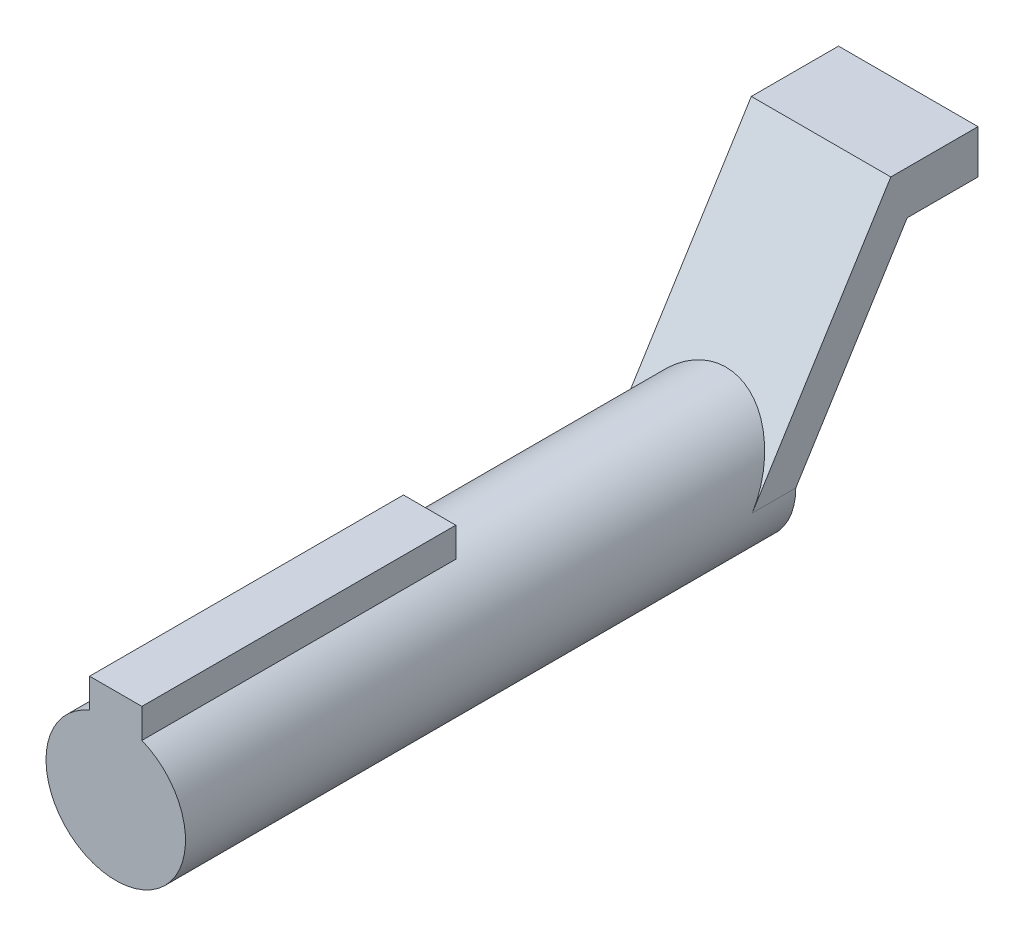
from build123d import *

# Parameters (mm, degrees)
SKETCH1_R                = 4
BOSS_EXTRUDE1_DEPTH      = 35
BOSS_EXTRUDE2_DEPTH      = 4
BOSS_EXTRUDE2_DEPTH_BACK = 4
SKETCH4_W                = 3
SKETCH4_H                = 5.4
BOSS_EXTRUDE3_DEPTH      = 18


with BuildPart() as part:
    # Sketch1 → Boss-Extrude1 (new body)
    with BuildSketch(Plane.XY):
        Circle(SKETCH1_R)
    extrude(amount=BOSS_EXTRUDE1_DEPTH)

    # Sketch2 → Boss-Extrude2 (add, two sides)
    with BuildSketch(Plane(origin=(0, 0, 0), x_dir=(0, 0, -1), z_dir=(1, 0, 0))) as boss_extrude2_sk:
        Polygon((5.4499841, 12.71997456), (-2.5, 0), (0, 0), (6.3874841, 10.21997456), (10.4499841, 10.21997456), (10.4499841, 12.71997456), (7.9499841, 12.71997456), align=None)
    extrude(amount=BOSS_EXTRUDE2_DEPTH)
    extrude(boss_extrude2_sk.sketch, amount=-BOSS_EXTRUDE2_DEPTH_BACK)

    # Sketch4 → Boss-Extrude3 (add)
    with BuildSketch(Plane.XY.offset(35)):
        with Locations((0, 2.7)):
            Rectangle(SKETCH4_W, SKETCH4_H)
    extrude(amount=-BOSS_EXTRUDE3_DEPTH)


solid = part.part
